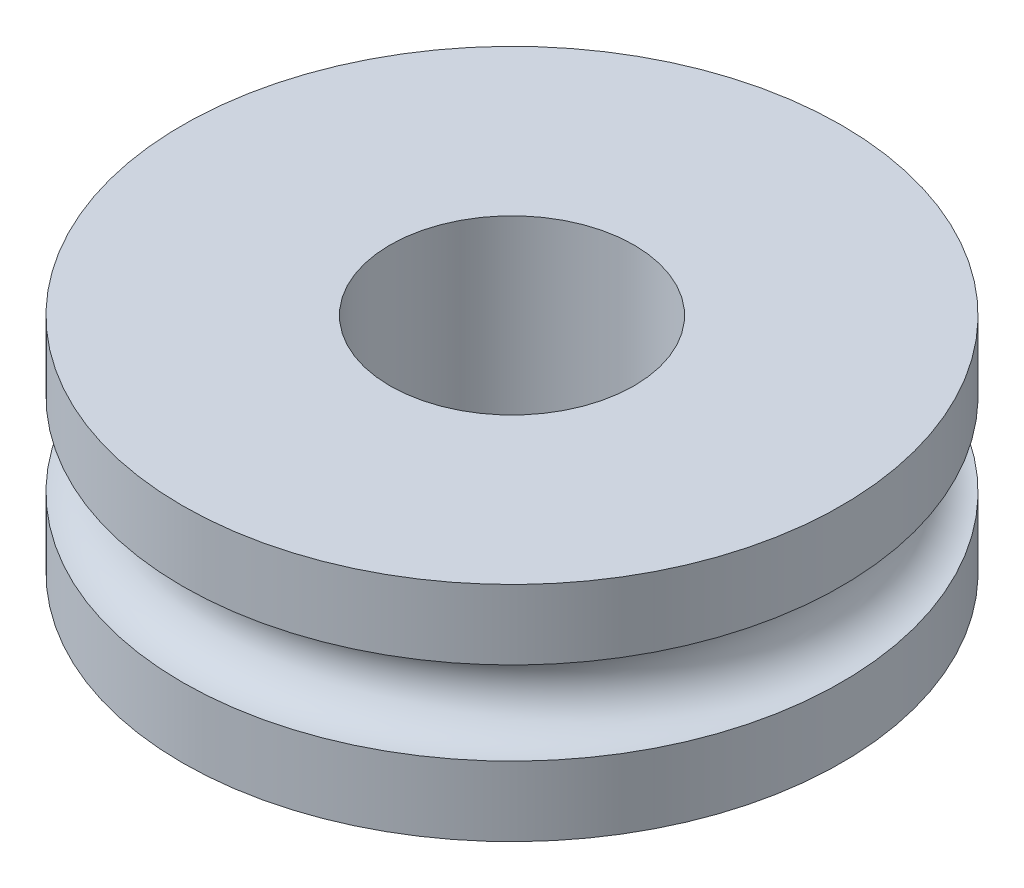
from build123d import *

# Parameters (mm, degrees)
SKETCH1_W = 47.908763192
SKETCH1_H = 51.416423574
SKETCH3_R = 9.608888213


with BuildPart() as part:
    # Sketch1 → Revolve1 (revolve)
    with BuildSketch(Plane.XY):
        with Locations((-52.129799597, 25.708211787)):
            Rectangle(SKETCH1_W, SKETCH1_H)
    revolve(axis=Axis((0, 0, 0), (0, 1, 0)))

    # Sketch3 → Cut-Revolve1 (revolve, cut)
    with BuildSketch(Plane.XY):
        with Locations((-76.084181193, 25.708211787)):
            Circle(SKETCH3_R)
    revolve(axis=Axis((0, 0, 0), (0, 1, 0)), mode=Mode.SUBTRACT)


solid = part.part
